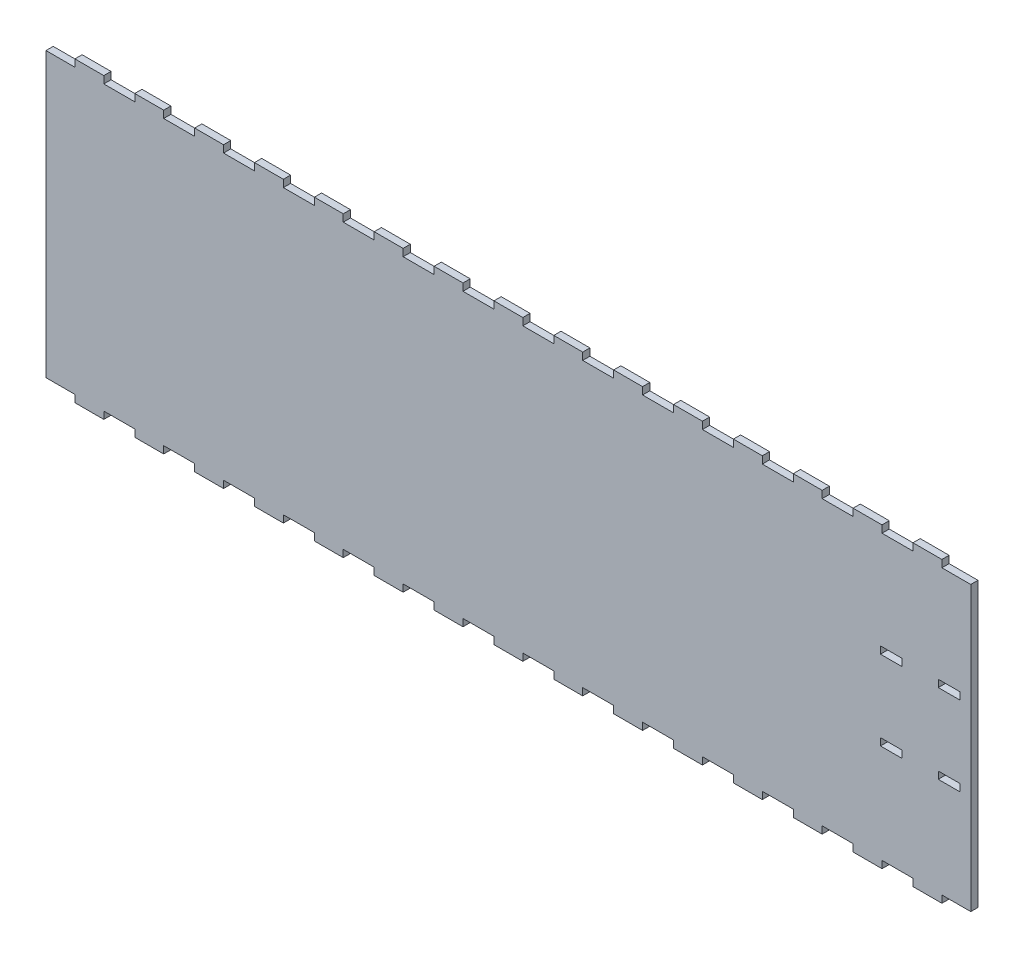
from build123d import *

# Parameters (mm, degrees)
SKETCH1_W           = 9.525
SKETCH1_H           = 3.175
BOSS_EXTRUDE1_DEPTH = 3.175


with BuildPart() as part:
    # Sketch1 → Boss-Extrude1 (new body)
    with BuildSketch(Plane.XY):
        Polygon((406.4, 0), (406.4, 124.5108), (393.7, 124.5108), (393.7, 127.6858), (381, 127.6858), (381, 124.5108), (367.392857143, 124.5108), (367.392857143, 127.6858), (354.692857143, 127.6858), (354.692857143, 124.5108), (341.085714286, 124.5108), (341.085714286, 127.6858), (328.385714286, 127.6858), (328.385714286, 124.5108), (314.778571429, 124.5108), (314.778571429, 127.6858), (302.078571429, 127.6858), (302.078571429, 124.5108), (288.471428571, 124.5108), (288.471428571, 127.6858), (275.771428571, 127.6858), (275.771428571, 124.5108), (262.164285714, 124.5108), (262.164285714, 127.6858), (249.464285714, 127.6858), (249.464285714, 124.5108), (235.857142857, 124.5108), (235.857142857, 127.6858), (223.157142857, 127.6858), (223.157142857, 124.5108), (209.55, 124.5108), (209.55, 127.6858), (196.85, 127.6858), (196.85, 124.5108), (183.242857143, 124.5108), (183.242857143, 127.6858), (170.542857143, 127.6858), (170.542857143, 124.5108), (156.935714286, 124.5108), (156.935714286, 127.6858), (144.235714286, 127.6858), (144.235714286, 124.5108), (130.628571429, 124.5108), (130.628571429, 127.6858), (117.928571429, 127.6858), (117.928571429, 124.5108), (104.321428571, 124.5108), (104.321428571, 127.6858), (91.621428571, 127.6858), (91.621428571, 124.5108), (78.014285714, 124.5108), (78.014285714, 127.6858), (65.314285714, 127.6858), (65.314285714, 124.5108), (51.707142857, 124.5108), (51.707142857, 127.6858), (39.007142857, 127.6858), (39.007142857, 124.5108), (25.4, 124.5108), (25.4, 127.6858), (12.7, 127.6858), (12.7, 124.5108), (0, 124.5108), (0, 0), (12.7, 0), (12.7, -3.175), (25.4, -3.175), (25.4, 0), (39.007142857, 0), (39.007142857, -3.175), (51.707142857, -3.175), (51.707142857, 0), (65.314285714, 0), (65.314285714, -3.175), (78.014285714, -3.175), (78.014285714, 0), (91.621428571, 0), (91.621428571, -3.175), (104.321428571, -3.175), (104.321428571, 0), (117.928571429, 0), (117.928571429, -3.175), (130.628571429, -3.175), (130.628571429, 0), (144.235714286, 0), (144.235714286, -3.175), (156.935714286, -3.175), (156.935714286, 0), (170.542857143, 0), (170.542857143, -3.175), (183.242857143, -3.175), (183.242857143, 0), (196.85, 0), (196.85, -3.175), (209.55, -3.175), (209.55, 0), (223.157142857, 0), (223.157142857, -3.175), (235.857142857, -3.175), (235.857142857, 0), (249.464285714, 0), (249.464285714, -3.175), (262.164285714, -3.175), (262.164285714, 0), (275.771428571, 0), (275.771428571, -3.175), (288.471428571, -3.175), (288.471428571, 0), (302.078571429, 0), (302.078571429, -3.175), (314.778571429, -3.175), (314.778571429, 0), (328.385714286, 0), (328.385714286, -3.175), (341.085714286, -3.175), (341.085714286, 0), (354.692857143, 0), (354.692857143, -3.175), (367.392857143, -3.175), (367.392857143, 0), (381, 0), (381, -3.175), (393.7, -3.175), (393.7, 0), align=None)
        with Locations((396.875, 79.7179)):
            Rectangle(SKETCH1_W, SKETCH1_H, mode=Mode.SUBTRACT)
        with Locations((396.875, 44.7929)):
            Rectangle(SKETCH1_W, SKETCH1_H, mode=Mode.SUBTRACT)
        with Locations((371.475, 79.7179)):
            Rectangle(SKETCH1_W, SKETCH1_H, mode=Mode.SUBTRACT)
        with Locations((371.475, 44.7929)):
            Rectangle(SKETCH1_W, SKETCH1_H, mode=Mode.SUBTRACT)
    extrude(amount=BOSS_EXTRUDE1_DEPTH)


solid = part.part
